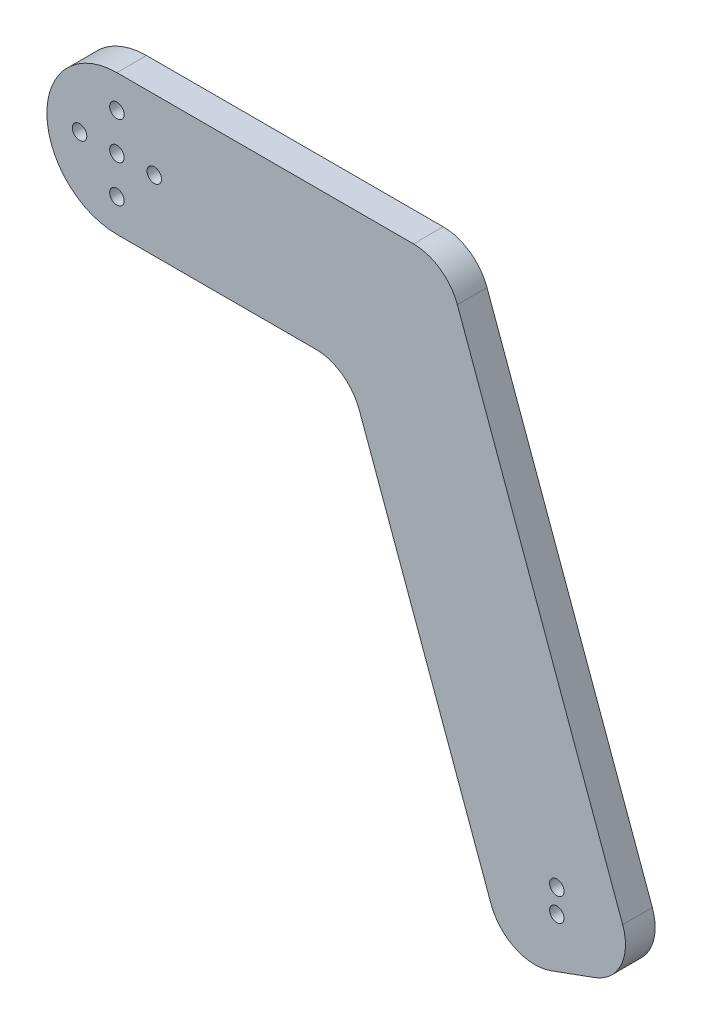
from build123d import *

# Parameters (mm, degrees)
SKETCH1_R           = 1.55
BOSS_EXTRUDE1_DEPTH = 6.35
FILLET1_R           = 10
FILLET2_R           = 10
SKETCH2_R           = 1.55
CUT_EXTRUDE1_DEPTH  = 10


with BuildPart() as part:
    # Sketch1 → Boss-Extrude1 (new body)
    with BuildSketch(Plane.XY):
        with BuildLine():
            ThreePointArc((0, 15), (-15, 0), (0, -15))
            Line((0, -15), (49.496886927, -15))
            Line((49.496886927, -15), (83.526826454, -108.496490436))
            Line((83.526826454, -108.496490436), (111.717605078, -98.235886137))
            Line((111.717605078, -98.235886137), (70.503113073, 15))
            Line((70.503113073, 15), (0, 15))
        make_face()
        with Locations((0, -8)):
            Circle(SKETCH1_R, mode=Mode.SUBTRACT)
        with Locations((-8, 0)):
            Circle(SKETCH1_R, mode=Mode.SUBTRACT)
        Circle(SKETCH1_R, mode=Mode.SUBTRACT)
        with Locations((0, 8)):
            Circle(SKETCH1_R, mode=Mode.SUBTRACT)
        with BuildLine():
            ThreePointArc((6.45, 0), (8, 1.55), (9.55, 0))
            ThreePointArc((9.55, 0), (8, -1.55), (6.45, 0))
        make_face(mode=Mode.SUBTRACT)
    extrude(amount=BOSS_EXTRUDE1_DEPTH)

    # Fillet1
    fillet1_edges = [part.edges().sort_by_distance(p)[0] for p in [
        (49.496886927, -15, 3.175),
        (70.503113073, 15, 3.175),
    ]]
    fillet(fillet1_edges, radius=FILLET1_R)

    # Fillet2
    fillet2_edges = [part.edges().sort_by_distance(p)[0] for p in [
        (111.717605078, -98.235886137, 3.175),
        (83.526826454, -108.496490436, 3.175),
    ]]
    fillet(fillet2_edges, radius=FILLET2_R)

    # Sketch2 → Cut-Extrude1 (cut)
    with BuildSketch(Plane.XY.offset(6.35)):
        with Locations((94.202014333, -93.969262079)):
            Circle(SKETCH2_R)
        with Locations((94.202014333, -88.969262079)):
            Circle(SKETCH2_R)
    extrude(amount=-CUT_EXTRUDE1_DEPTH, mode=Mode.SUBTRACT)


solid = part.part
